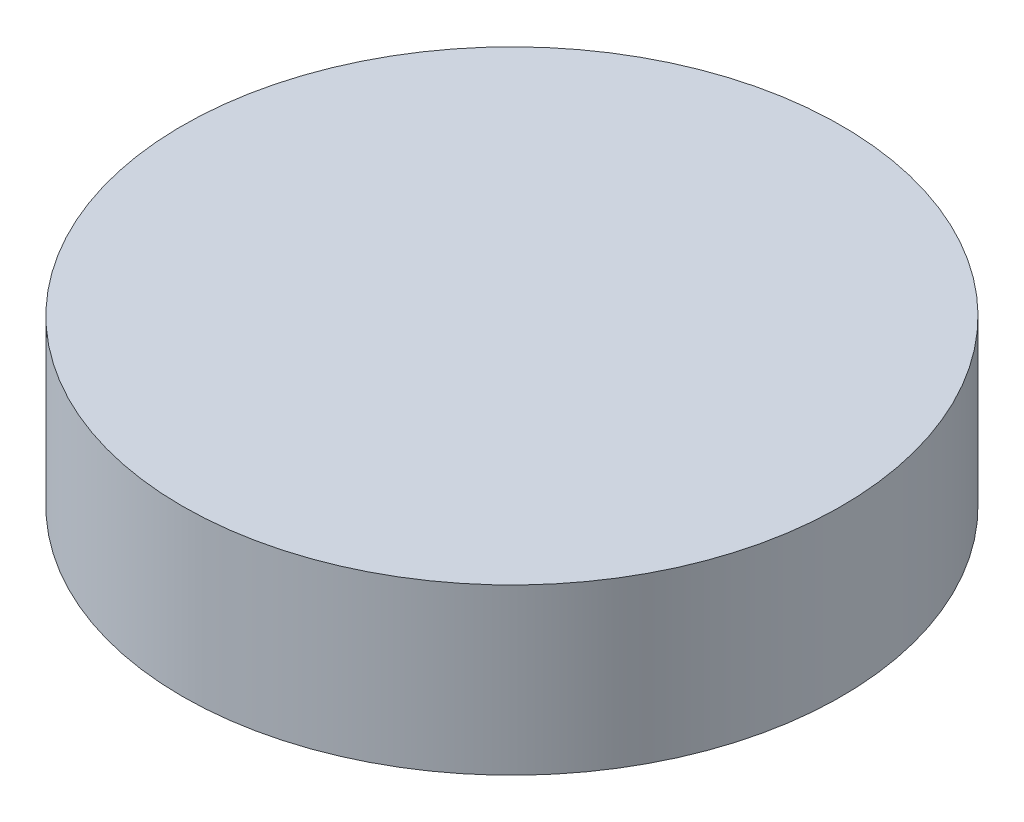
from build123d import *

# Parameters (mm, degrees)
SKETCH_1_R      = 25.4
EXTRUDE_1_DEPTH = 12.7


with BuildPart() as part:
    # 草图1 → 凸台-拉伸1 (new body)
    with BuildSketch(Plane(origin=(0, 0, 0), x_dir=(1, 0, 0), z_dir=(0, 1, 0))):
        with Locations(Location((0, 0, 0), (0, 0, 270))):  # turned: the seam where the file's is
            Circle(SKETCH_1_R)
    extrude(amount=EXTRUDE_1_DEPTH)


solid = part.part
